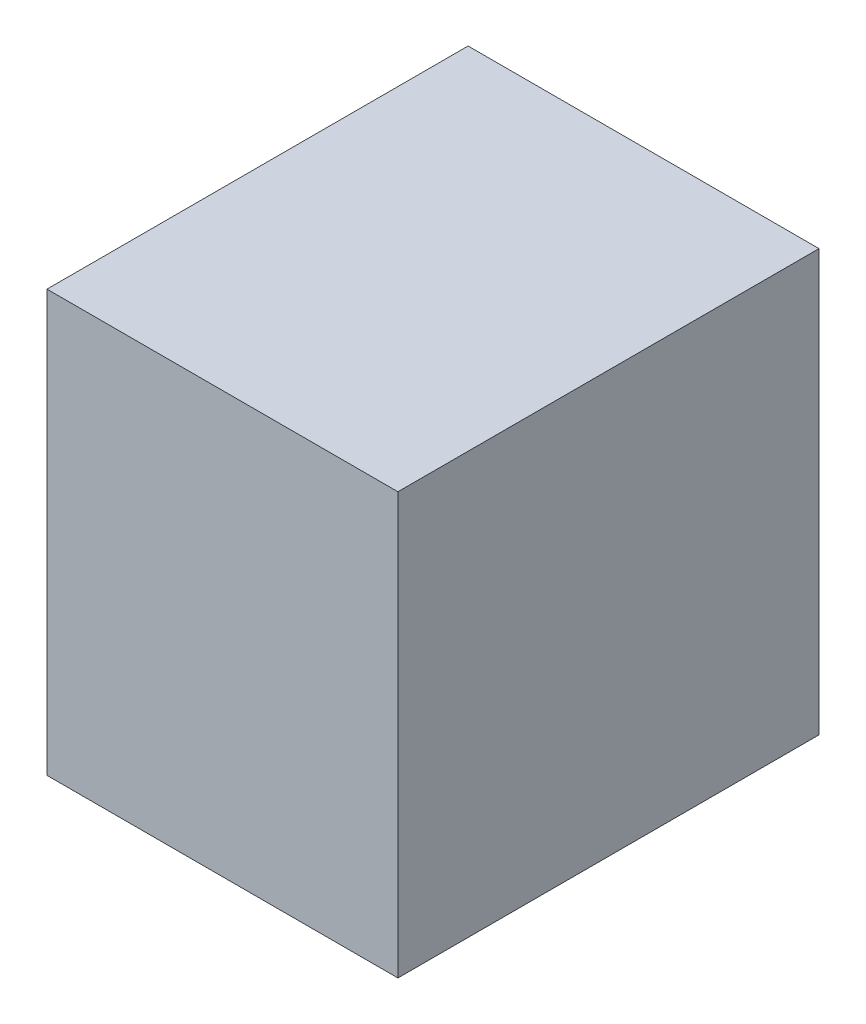
from build123d import *

# Parameters (mm, degrees)
SKETCH1_W           = 508
SKETCH1_H           = 609.6
BOSS_EXTRUDE1_DEPTH = 609.6


with BuildPart() as part:
    # Sketch1 → Boss-Extrude1 (new body)
    with BuildSketch(Plane(origin=(0, 0, 0), x_dir=(1, 0, 0), z_dir=(0, 1, 0))):
        Rectangle(SKETCH1_W, SKETCH1_H)
    extrude(amount=BOSS_EXTRUDE1_DEPTH)


solid = part.part
